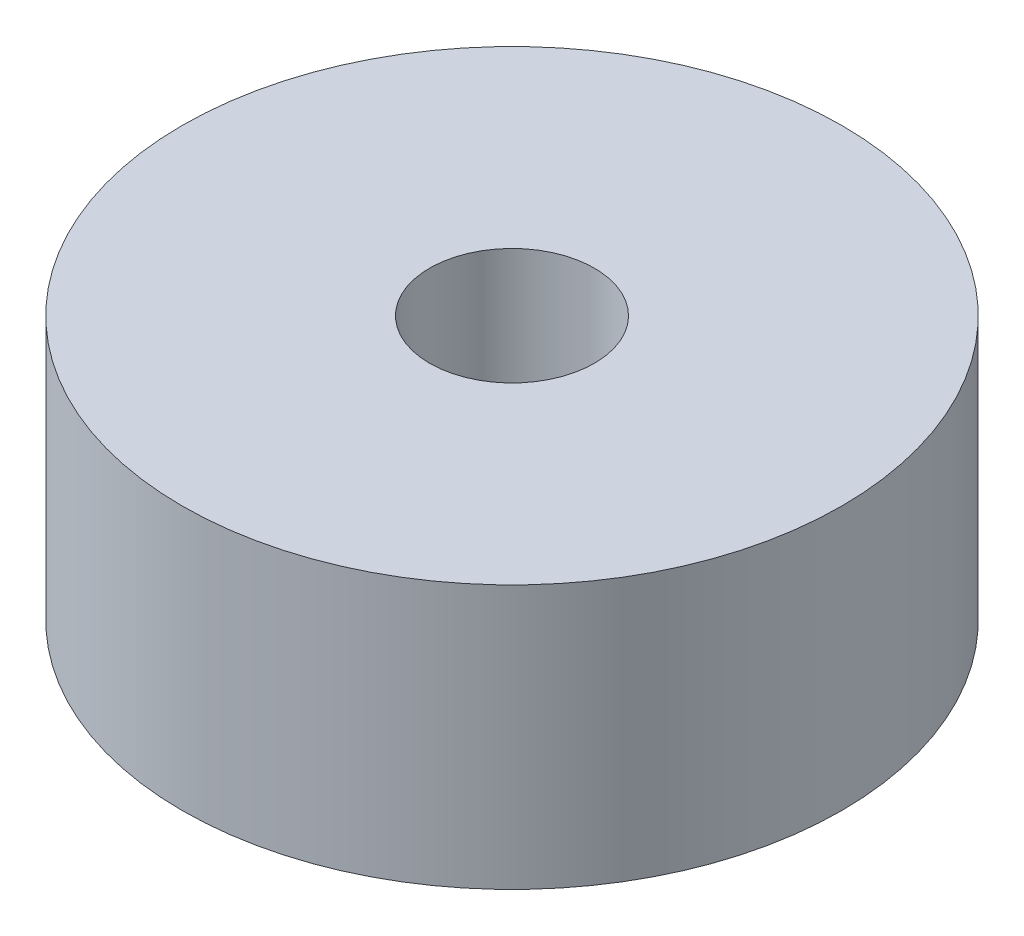
from build123d import *

# Parameters (mm, degrees)
CROQUIS1_R              = 25.4
CROQUIS1_R_2            = 6.35
SALIENTE_EXTRUIR1_DEPTH = 20.32


with BuildPart() as part:
    # Croquis1 → Saliente-Extruir1 (new body)
    with BuildSketch(Plane(origin=(0, 0, 0), x_dir=(1, 0, 0), z_dir=(0, 1, 0))):
        Circle(CROQUIS1_R)
        Circle(CROQUIS1_R_2, mode=Mode.SUBTRACT)
    extrude(amount=SALIENTE_EXTRUIR1_DEPTH)


solid = part.part
